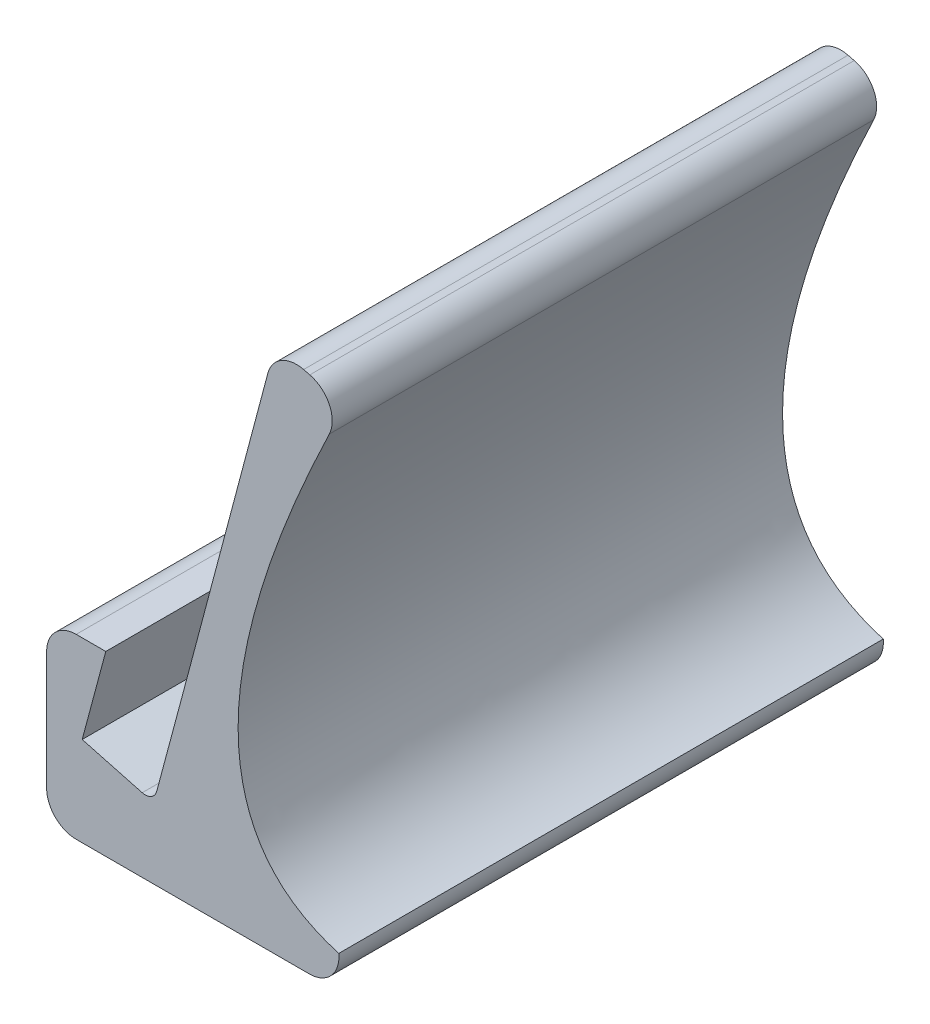
from build123d import *

# Parameters (mm, degrees)
BOSS_EXTRUDE1_DEPTH = 92
BOSS_EXTRUDE2_DEPTH = 5
BOSS_EXTRUDE3_START = 5
BOSS_EXTRUDE3_DEPTH = 30


with BuildPart() as part:
    # Sketch1 → Boss-Extrude1 (new body)
    with BuildSketch(Plane.XY):
        with BuildLine():
            ThreePointArc((43.43198058, 87.971890028), (39.678375933, 87.427416305), (37.386921991, 84.40496063))
            Line((37.386921991, 84.40496063), (30.160238403, 57.202480315))
            Line((30.160238403, 57.202480315), (22.933554815, 30))
            Line((22.933554815, 30), (18.60433255, 13.818460639))
            ThreePointArc((18.60433255, 13.818460639), (17.672613775, 12.603502297), (16.154645697, 12.403510891))
            Line((16.154645697, 12.403510891), (6.013160809, 15.120913577))
            Line((6.013160809, 15.120913577), (10, 30))
            Line((10, 30), (5, 30))
            ThreePointArc((5, 30), (1.464466094, 28.535533906), (0, 25))
            Line((0, 25), (0, 5))
            ThreePointArc((0, 5), (1.464466094, 1.464466094), (5, 0))
            Line((5, 0), (44.402158914, 0))
            ThreePointArc((44.402158914, 0), (48.110924034, 1.646634335), (49.376897159, 5.501975487))
            add(Edge.make_bspline(
                [(47.769018508, 80.690333507), (37.23731495, 58.823324345), (26.973591169, 24.424922179), (38.309234052, 8.697752331), (49.376897159, 5.501975487)],
                knots=[0.034365073, 0.034365073, 0.034365073, 0.034365073, 0.450207032, 0.866048991, 0.866048991, 0.866048991, 0.866048991], degree=3))
            ThreePointArc((47.769018508, 80.690333507), (47.791234842, 84.982795953), (44.476941442, 87.710649813))
            Line((44.476941442, 87.710649813), (43.43198058, 87.971890028))
        make_face()
    extrude(amount=BOSS_EXTRUDE1_DEPTH)

    # Sketch1_3 → Boss-Extrude2 (add)
    with BuildSketch(Plane.XY):
        with BuildLine():
            Line((22.933554815, 30), (30.160238403, 57.202480315))
            Line((30.160238403, 57.202480315), (22.508418768, 59.201215835))
            ThreePointArc((22.508418768, 59.201215835), (18.694880172, 58.664472736), (16.394052668, 55.576210673))
            Line((16.394052668, 55.576210673), (13.75675976, 45.027039041))
            Line((13.75675976, 45.027039041), (16.890316486, 44.243649859))
            Line((16.890316486, 44.243649859), (17.860458987, 48.12421986))
            Line((17.860458987, 48.12421986), (21.013422112, 47.335979078))
            ThreePointArc((21.013422112, 47.335979078), (22.468635862, 44.910622828), (20.043279612, 43.455409078))
            Line((20.043279612, 43.455409078), (19.194404924, 40.059910327))
            Line((19.194404924, 40.059910327), (12.907885073, 41.63154029))
            Line((12.907885073, 41.63154029), (10, 30))
            Line((10, 30), (6.013160809, 15.120913577))
            Line((6.013160809, 15.120913577), (16.154645697, 12.403510891))
            ThreePointArc((16.154645697, 12.403510891), (17.672613775, 12.603502297), (18.60433255, 13.818460639))
            Line((18.60433255, 13.818460639), (22.933554815, 30))
        make_face()
    extrude(amount=BOSS_EXTRUDE2_DEPTH)

    # Sketch1_4 → Boss-Extrude3 (add)
    with BuildSketch(Plane.XY.offset(BOSS_EXTRUDE3_START)):
        with BuildLine():
            Line((22.933554815, 30), (30.160238403, 57.202480315))
            Line((30.160238403, 57.202480315), (22.508418768, 59.201215835))
            ThreePointArc((22.508418768, 59.201215835), (18.694880172, 58.664472736), (16.394052668, 55.576210673))
            Line((16.394052668, 55.576210673), (14.72690226, 48.907609041))
            Line((14.72690226, 48.907609041), (13.75675976, 45.027039041))
            Line((13.75675976, 45.027039041), (16.890316486, 44.243649859))
            Line((16.890316486, 44.243649859), (17.860458987, 48.12421986))
            Line((17.860458987, 48.12421986), (18.709333674, 51.51971861))
            Line((18.709333674, 51.51971861), (25.015259925, 49.943237047))
            Line((25.015259925, 49.943237047), (22.34736805, 39.271669546))
            Line((22.34736805, 39.271669546), (19.194404924, 40.059910327))
            Line((19.194404924, 40.059910327), (16.041441799, 40.848151108))
            Line((16.041441799, 40.848151108), (12.907885073, 41.63154029))
            Line((12.907885073, 41.63154029), (10, 30))
            Line((10, 30), (6.013160809, 15.120913577))
            Line((6.013160809, 15.120913577), (16.154645697, 12.403510891))
            ThreePointArc((16.154645697, 12.403510891), (17.672613775, 12.603502297), (18.60433255, 13.818460639))
            Line((18.60433255, 13.818460639), (22.933554815, 30))
        make_face()
    extrude(amount=BOSS_EXTRUDE3_DEPTH)


solid = part.part
